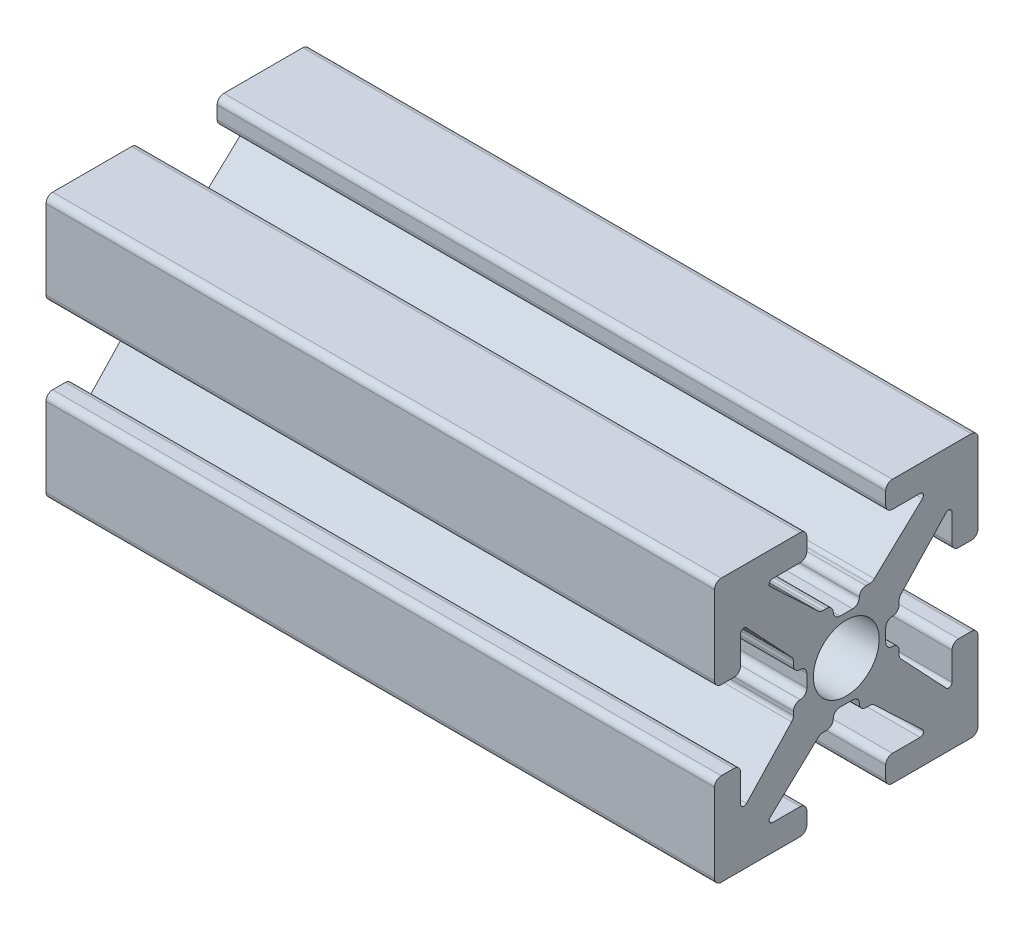
from build123d import *

# Parameters (mm, degrees)
ESTRUSIONE_ESTRUSIONE1_DEPTH = 25.4
FORO_FILETTATO_M3X0_5_1_D    = 2.5


with BuildPart() as part:
    # Sketch1 → Estrusione-Estrusione1 (new body)
    with BuildSketch(Plane(origin=(0, 0, 0), x_dir=(0, 0, -1), z_dir=(1, 0, 0))):
        with BuildLine():
            Line((-0.2413, 1.4986), (0.2413, 1.4986))
            ThreePointArc((0.2413, 1.4986), (0.420905122, 1.572994878), (0.4953, 1.7526))
            ThreePointArc((0.4953, 1.7526), (0.569694878, 1.932205122), (0.7493, 2.0066))
            Line((0.7493, 2.0066), (0.889923986, 2.0066))
            ThreePointArc((0.889923986, 2.0066), (0.983516259, 2.024471886), (1.063937899, 2.075572548))
            Line((1.063937899, 2.075572548), (2.890793, 3.793686274))
            ThreePointArc((2.890793, 3.793686274), (2.921850101, 3.932996137), (2.803786044, 4.0132))
            Line((2.803786044, 4.0132), (1.7526, 4.0132))
            ThreePointArc((1.7526, 4.0132), (1.572994878, 4.087594878), (1.4986, 4.2672))
            Line((1.4986, 4.2672), (1.4986, 4.7498))
            ThreePointArc((1.4986, 4.7498), (1.572994878, 4.929405122), (1.7526, 5.0038))
            Line((1.7526, 5.0038), (4.7498, 5.0038))
            ThreePointArc((4.7498, 5.0038), (4.929405122, 4.929405122), (5.0038, 4.7498))
            Line((5.0038, 4.7498), (5.0038, 1.7526))
            ThreePointArc((5.0038, 1.7526), (4.929405122, 1.572994878), (4.7498, 1.4986))
            Line((4.7498, 1.4986), (4.2672, 1.4986))
            ThreePointArc((4.2672, 1.4986), (4.087594878, 1.572994878), (4.0132, 1.7526))
            Line((4.0132, 1.7526), (4.0132, 2.803786044))
            ThreePointArc((4.0132, 2.803786044), (3.932996137, 2.921850101), (3.793686274, 2.890793))
            Line((3.793686274, 2.890793), (2.075572548, 1.063937899))
            ThreePointArc((2.075572548, 1.063937899), (2.024471886, 0.983516259), (2.0066, 0.889923986))
            Line((2.0066, 0.889923986), (2.0066, 0.7493))
            ThreePointArc((2.0066, 0.7493), (1.932205122, 0.569694878), (1.7526, 0.4953))
            ThreePointArc((1.7526, 0.4953), (1.572994878, 0.420905122), (1.4986, 0.2413))
            Line((1.4986, 0.2413), (1.4986, -0.2413))
            ThreePointArc((1.4986, -0.2413), (1.572994878, -0.420905122), (1.7526, -0.4953))
            ThreePointArc((1.7526, -0.4953), (1.932205122, -0.569694878), (2.0066, -0.7493))
            Line((2.0066, -0.7493), (2.0066, -0.889923986))
            ThreePointArc((2.0066, -0.889923986), (2.024471886, -0.983516259), (2.075572548, -1.063937899))
            Line((2.075572548, -1.063937899), (3.793686274, -2.890793))
            ThreePointArc((3.793686274, -2.890793), (3.932996137, -2.921850101), (4.0132, -2.803786044))
            Line((4.0132, -2.803786044), (4.0132, -1.7526))
            ThreePointArc((4.0132, -1.7526), (4.087594878, -1.572994878), (4.2672, -1.4986))
            Line((4.2672, -1.4986), (4.7498, -1.4986))
            ThreePointArc((4.7498, -1.4986), (4.929405122, -1.572994878), (5.0038, -1.7526))
            Line((5.0038, -1.7526), (5.0038, -4.7498))
            ThreePointArc((5.0038, -4.7498), (4.929405122, -4.929405122), (4.7498, -5.0038))
            Line((4.7498, -5.0038), (1.7526, -5.0038))
            ThreePointArc((1.7526, -5.0038), (1.572994878, -4.929405122), (1.4986, -4.7498))
            Line((1.4986, -4.7498), (1.4986, -4.2672))
            ThreePointArc((1.4986, -4.2672), (1.572994878, -4.087594878), (1.7526, -4.0132))
            Line((1.7526, -4.0132), (2.803786044, -4.0132))
            ThreePointArc((2.803786044, -4.0132), (2.921850101, -3.932996137), (2.890793, -3.793686274))
            Line((2.890793, -3.793686274), (1.063937899, -2.075572548))
            ThreePointArc((1.063937899, -2.075572548), (0.983516259, -2.024471886), (0.889923986, -2.0066))
            Line((0.889923986, -2.0066), (0.7493, -2.0066))
            ThreePointArc((0.7493, -2.0066), (0.569694878, -1.932205122), (0.4953, -1.7526))
            ThreePointArc((0.4953, -1.7526), (0.420905122, -1.572994878), (0.2413, -1.4986))
            Line((0.2413, -1.4986), (-0.2413, -1.4986))
            ThreePointArc((-0.2413, -1.4986), (-0.420905122, -1.572994878), (-0.4953, -1.7526))
            ThreePointArc((-0.4953, -1.7526), (-0.569694878, -1.932205122), (-0.7493, -2.0066))
            Line((-0.7493, -2.0066), (-0.889923986, -2.0066))
            ThreePointArc((-0.889923986, -2.0066), (-0.983516259, -2.024471886), (-1.063937899, -2.075572548))
            Line((-1.063937899, -2.075572548), (-2.890793, -3.793686274))
            ThreePointArc((-2.890793, -3.793686274), (-2.921850101, -3.932996137), (-2.803786044, -4.0132))
            Line((-2.803786044, -4.0132), (-1.7526, -4.0132))
            ThreePointArc((-1.7526, -4.0132), (-1.572994878, -4.087594878), (-1.4986, -4.2672))
            Line((-1.4986, -4.2672), (-1.4986, -4.7498))
            ThreePointArc((-1.4986, -4.7498), (-1.572994878, -4.929405122), (-1.7526, -5.0038))
            Line((-1.7526, -5.0038), (-4.7498, -5.0038))
            ThreePointArc((-4.7498, -5.0038), (-4.929405122, -4.929405122), (-5.0038, -4.7498))
            Line((-5.0038, -4.7498), (-5.0038, -1.7526))
            ThreePointArc((-5.0038, -1.7526), (-4.929405122, -1.572994878), (-4.7498, -1.4986))
            Line((-4.7498, -1.4986), (-4.2672, -1.4986))
            ThreePointArc((-4.2672, -1.4986), (-4.087594878, -1.572994878), (-4.0132, -1.7526))
            Line((-4.0132, -1.7526), (-4.0132, -2.803786044))
            ThreePointArc((-4.0132, -2.803786044), (-3.932996137, -2.921850101), (-3.793686274, -2.890793))
            Line((-3.793686274, -2.890793), (-2.075572548, -1.063937899))
            ThreePointArc((-2.075572548, -1.063937899), (-2.024471886, -0.983516259), (-2.0066, -0.889923986))
            Line((-2.0066, -0.889923986), (-2.0066, -0.7493))
            ThreePointArc((-2.0066, -0.7493), (-1.932205122, -0.569694878), (-1.7526, -0.4953))
            ThreePointArc((-1.7526, -0.4953), (-1.572994878, -0.420905122), (-1.4986, -0.2413))
            Line((-1.4986, -0.2413), (-1.4986, 0.2413))
            ThreePointArc((-1.4986, 0.2413), (-1.572994878, 0.420905122), (-1.7526, 0.4953))
            ThreePointArc((-1.7526, 0.4953), (-1.932205122, 0.569694878), (-2.0066, 0.7493))
            Line((-2.0066, 0.7493), (-2.0066, 0.889923986))
            ThreePointArc((-2.0066, 0.889923986), (-2.024471886, 0.983516259), (-2.075572548, 1.063937899))
            Line((-2.075572548, 1.063937899), (-3.793686274, 2.890793))
            ThreePointArc((-3.793686274, 2.890793), (-3.932996137, 2.921850101), (-4.0132, 2.803786044))
            Line((-4.0132, 2.803786044), (-4.0132, 1.7526))
            ThreePointArc((-4.0132, 1.7526), (-4.087594878, 1.572994878), (-4.2672, 1.4986))
            Line((-4.2672, 1.4986), (-4.7498, 1.4986))
            ThreePointArc((-4.7498, 1.4986), (-4.929405122, 1.572994878), (-5.0038, 1.7526))
            Line((-5.0038, 1.7526), (-5.0038, 4.7498))
            ThreePointArc((-5.0038, 4.7498), (-4.929405122, 4.929405122), (-4.7498, 5.0038))
            Line((-4.7498, 5.0038), (-1.7526, 5.0038))
            ThreePointArc((-1.7526, 5.0038), (-1.572994878, 4.929405122), (-1.4986, 4.7498))
            Line((-1.4986, 4.7498), (-1.4986, 4.2672))
            ThreePointArc((-1.4986, 4.2672), (-1.572994878, 4.087594878), (-1.7526, 4.0132))
            Line((-1.7526, 4.0132), (-2.803786044, 4.0132))
            ThreePointArc((-2.803786044, 4.0132), (-2.921850101, 3.932996137), (-2.890793, 3.793686274))
            Line((-2.890793, 3.793686274), (-1.063937899, 2.075572548))
            ThreePointArc((-1.063937899, 2.075572548), (-0.983516259, 2.024471886), (-0.889923986, 2.0066))
            Line((-0.889923986, 2.0066), (-0.7493, 2.0066))
            ThreePointArc((-0.7493, 2.0066), (-0.569694878, 1.932205122), (-0.4953, 1.7526))
            ThreePointArc((-0.4953, 1.7526), (-0.420905122, 1.572994878), (-0.2413, 1.4986))
        make_face()
    extrude(amount=ESTRUSIONE_ESTRUSIONE1_DEPTH)

    # Foro filettato M3x0.5-1 (through all)
    with Locations(Plane.ZY):
        with Locations((0, 0)):
            Hole(FORO_FILETTATO_M3X0_5_1_D / 2)


solid = part.part
